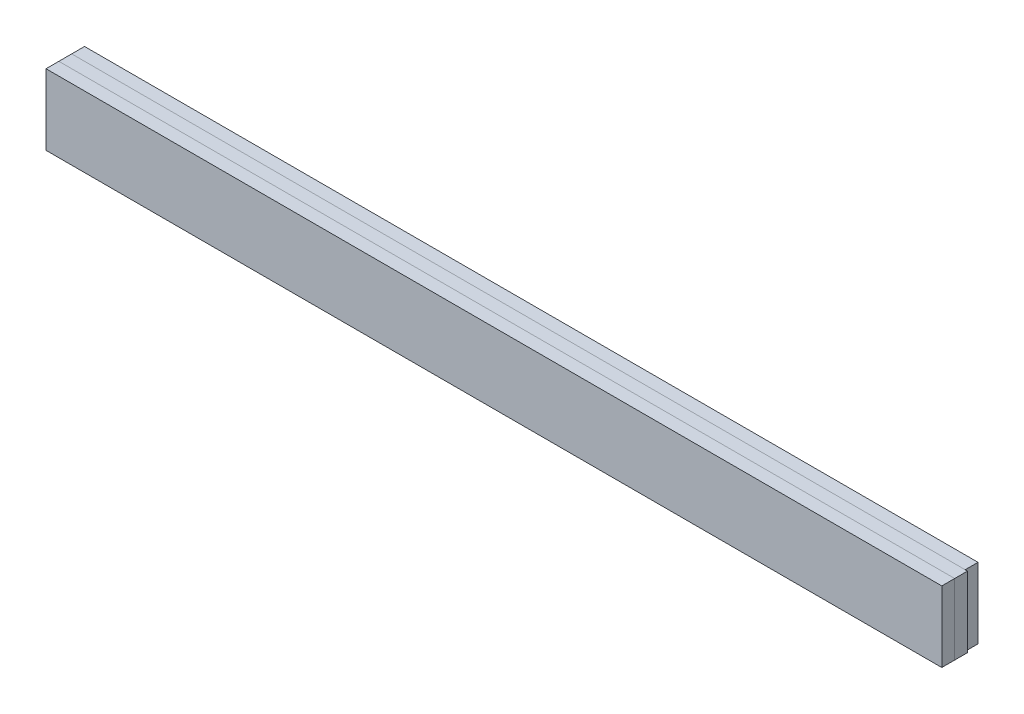
from build123d import *

# Parameters (mm, degrees)
SKETCH1_W           = 69.7
SKETCH1_H           = 5.5
BOSS_EXTRUDE1_DEPTH = 0.5
SKETCH2_W           = 69.7
SKETCH2_H           = 5.5
BOSS_EXTRUDE2_DEPTH = 1
SKETCH3_W           = 69.517480874
SKETCH3_H           = 5.5
BOSS_EXTRUDE3_DEPTH = 1


with BuildPart() as part:
    # Sketch1 → Boss-Extrude1 (new body, symmetric)
    with BuildSketch(Plane.XY):
        with Locations((0, 2.75)):
            Rectangle(SKETCH1_W, SKETCH1_H)
    extrude(amount=BOSS_EXTRUDE1_DEPTH, both=True)


with BuildPart() as body_2:
    # Sketch2 → Boss-Extrude2 (new body)
    with BuildSketch(Plane.XY.offset(0.5)):
        with Locations((0, 2.75)):
            Rectangle(SKETCH2_W, SKETCH2_H)
    extrude(amount=BOSS_EXTRUDE2_DEPTH)


with BuildPart() as body_3:
    # Sketch3 → Boss-Extrude3 (new body)
    with BuildSketch(Plane(origin=(0, 0, -0.5), x_dir=(-1, 0, 0), z_dir=(0, 0, -1))):
        with Locations((0.091259563, 2.75)):
            Rectangle(SKETCH3_W, SKETCH3_H)
    extrude(amount=BOSS_EXTRUDE3_DEPTH)


solid = Compound([part.part, body_2.part, body_3.part])
